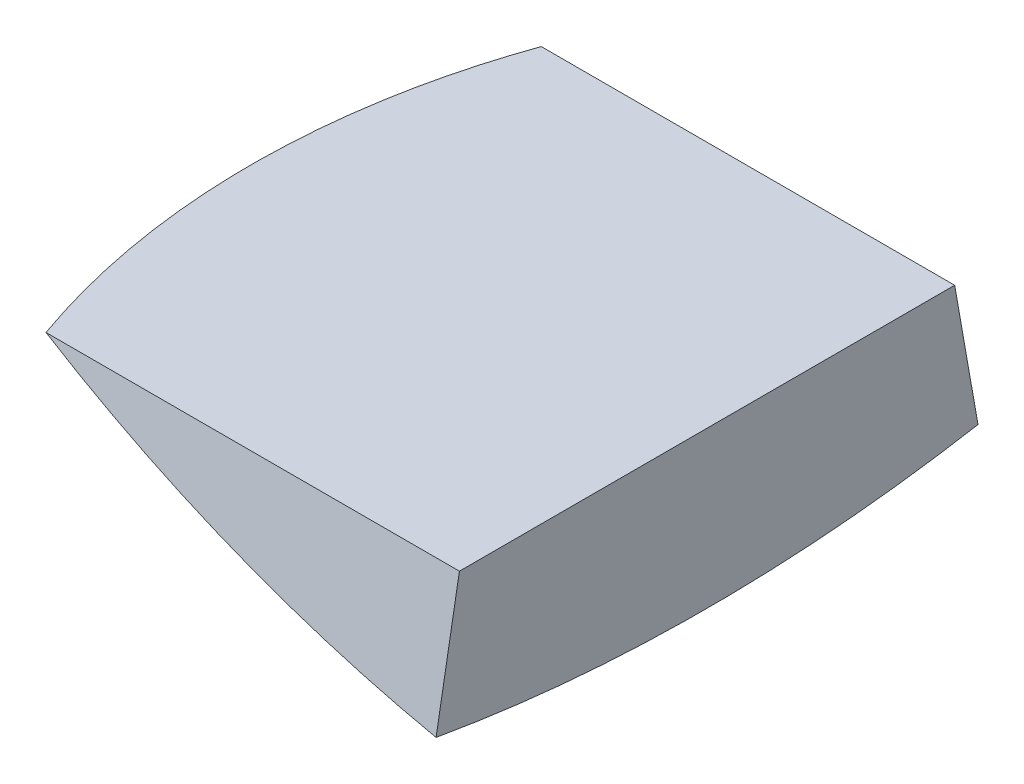
from build123d import *

# Parameters (mm, degrees)
REVOLVE1_ANGLE     = 20
SKETCH2_W          = 412.295717077
SKETCH2_H          = 77.070568273
CUT_EXTRUDE1_DEPTH = 249.770836259


with BuildPart() as part:
    # Sketch1 → Revolve1 (revolve, symmetric)
    with BuildSketch(Plane.XY) as revolve1_sk:
        with BuildLine():
            Line((-110.266592819, -625.352923163), (-110.266592819, -523.752923163))
            Line((-110.266592819, -523.752923163), (-359.037429077, -523.752923163))
            ThreePointArc((-359.037429077, -523.752923163), (-240.087913569, -587.86290388), (-110.266592819, -625.352923163))
        make_face()
    revolve(axis=Axis((22.053318564, 9.647076837, 0), (-1, 0, 0)), revolution_arc=REVOLVE1_ANGLE / 2)
    revolve(revolve1_sk.sketch, axis=Axis((22.053318564, 9.647076837, 0), (1, 0, 0)), revolution_arc=REVOLVE1_ANGLE / 2)

    # Sketch2 → Cut-Extrude1 (cut, through all)
    with BuildSketch(Plane(origin=(-110.266592819, 0, 0), x_dir=(0, 0, -1), z_dir=(1, 0, 0))):
        with Locations((-11.149391639, -523.317639027)):
            Rectangle(SKETCH2_W, SKETCH2_H)
    extrude(amount=-CUT_EXTRUDE1_DEPTH, mode=Mode.SUBTRACT)


solid = part.part
